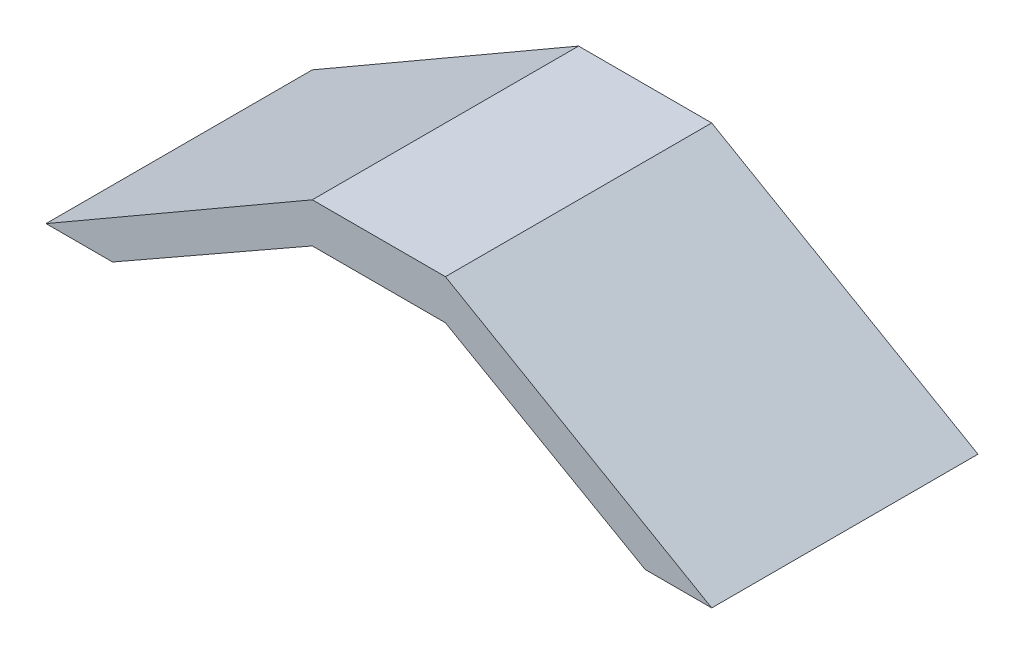
from build123d import *

# Parameters (mm, degrees)
BOSS_EXTRUDE1_DEPTH = 2000


with BuildPart() as part:
    # Sketch1 → Boss-Extrude1 (new body)
    with BuildSketch(Plane.XY):
        Polygon((0, 854.700538379), (1500, 0), (2000, 0), (0, 1154.700538379), (-1000, 1154.700538379), (-3000, 0), (-2500, 0), (-1000, 854.700538379), align=None)
    extrude(amount=-BOSS_EXTRUDE1_DEPTH)


solid = part.part
